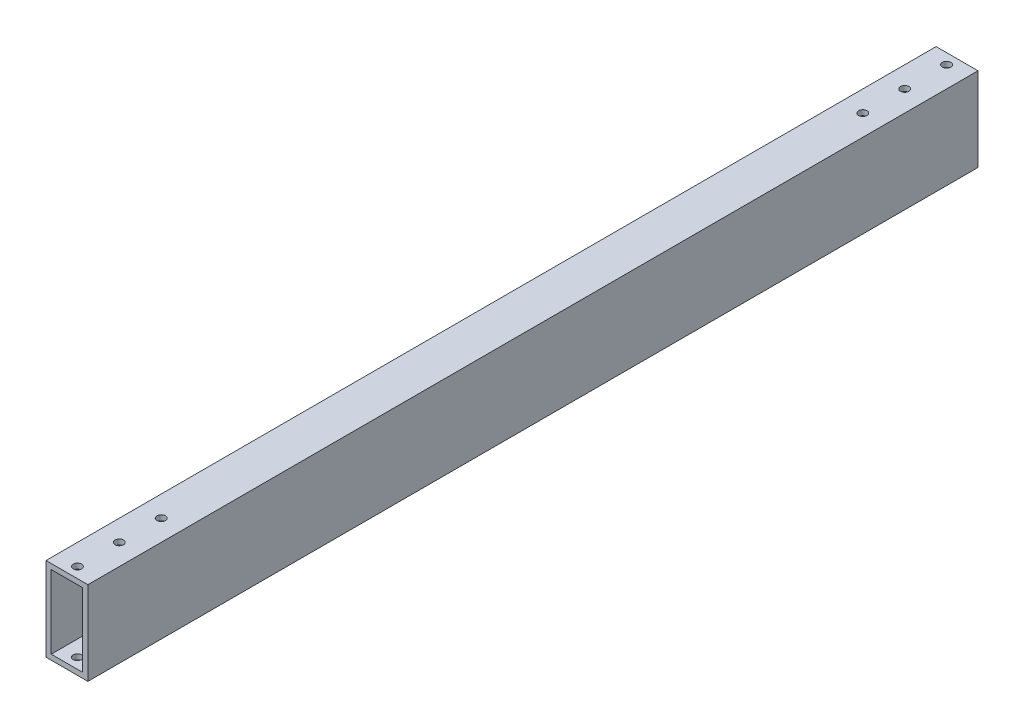
from build123d import *

# Parameters (mm, degrees)
SKETCH1_W                       = 25.4
SKETCH1_H                       = 50.8
SKETCH1_W_2                     = 19.05
SKETCH1_H_2                     = 44.45
EXTRUDE_THIN1_DEPTH             = 539.75
F_10_CLEARANCE_HOLE1_D          = 5.1054
M4X0_7_TAPPED_HOLE1_D           = 3.3
M4X0_7_TAPPED_HOLE1_DEPTH       = 3.175
F_1_8_0_13_DIAMETER_HOLE1_D     = 3.302
F_1_8_0_13_DIAMETER_HOLE1_DEPTH = 3.175


with BuildPart() as part:
    # Sketch1 → Extrude-Thin1 (new body)
    with BuildSketch(Plane.XY):
        Rectangle(SKETCH1_W, SKETCH1_H)
        Rectangle(SKETCH1_W_2, SKETCH1_H_2, mode=Mode.SUBTRACT)
    extrude(amount=EXTRUDE_THIN1_DEPTH)

    # #10 Clearance Hole1 (through all)
    with Locations(Plane(origin=(0, 25.4, 0), x_dir=(1, 0, 0), z_dir=(0, 1, 0))):
        with Locations((0, -533.4), (0, -508), (0, -482.6), (0, -6.35), (0, -31.75), (0, -57.15)):
            Hole(F_10_CLEARANCE_HOLE1_D / 2)

    # M4x0.7 Tapped Hole1
    with Locations(Plane.ZY.offset(12.7)):
        with Locations((148.968, 0), (88.968, 0), (28.968, 0), (208.968, 0), (268.968, 0), (328.968, 0), (388.968, 0), (448.968, 0), (508.968, 0)):
            Hole(M4X0_7_TAPPED_HOLE1_D / 2, depth=M4X0_7_TAPPED_HOLE1_DEPTH)

    # 1/8 (0.13) Diameter Hole1
    with Locations(Plane(origin=(0, -25.4, 0), x_dir=(-1, 0, 0), z_dir=(0, -1, 0))):
        with Locations((3.175, -70.358), (-3.175, -95.758), (3.175, -127.508), (-3.175, -152.908), (3.175, -184.658), (3.175, -241.808), (-3.175, -267.208), (2.890210973, -300.584252198), (-3.175, -324.358), (3.175, -356.108), (-3.175, -381.508), (3.175, -413.258), (-3.175, -438.658), (3.175, -470.408), (-3.175, -210.058)):
            Hole(F_1_8_0_13_DIAMETER_HOLE1_D / 2, depth=F_1_8_0_13_DIAMETER_HOLE1_DEPTH)


solid = part.part
